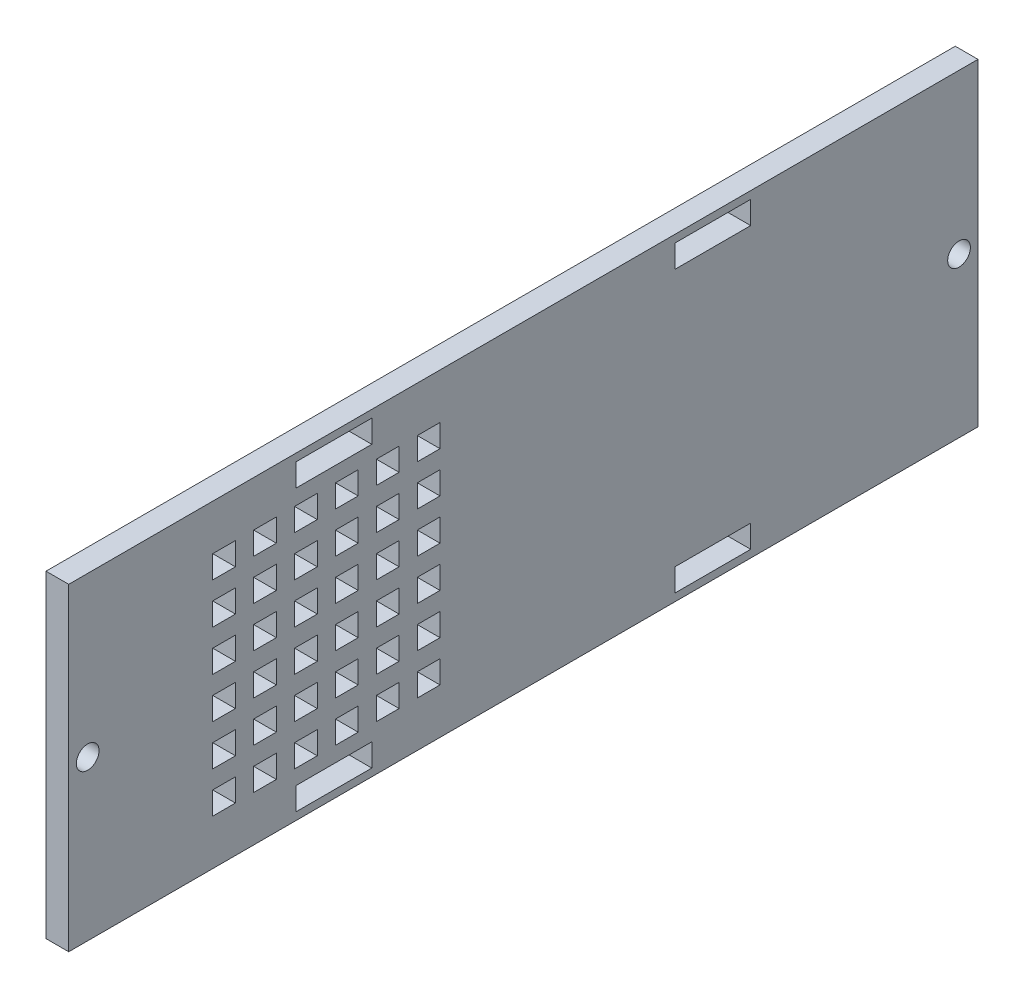
from build123d import *

# Parameters (mm, degrees)
SKETCH1_W            = 120
SKETCH1_H            = 42
SKETCH1_R            = 1.5
SKETCH1_W_2          = 10
SKETCH1_H_2          = 3
BOSS_EXTRUDE1_DEPTH  = 3
SKETCH2_W            = 3
SKETCH2_H            = 3
CUT_EXTRUDE1_DEPTH   = 3
LPATTERN1_COUNT      = 6
LPATTERN1_PITCH      = 5.4
LPATTERN1_COUNT_DIR2 = 6
LPATTERN1_PITCH_DIR2 = 5.4


with BuildPart() as part:
    # Sketch1 → Boss-Extrude1 (new body)
    with BuildSketch(Plane(origin=(0, 0, 0), x_dir=(0, 0, -1), z_dir=(1, 0, 0))):
        Rectangle(SKETCH1_W, SKETCH1_H)
        with Locations((-57.5, 0)):
            Circle(SKETCH1_R, mode=Mode.SUBTRACT)
        with Locations((57.5, 0)):
            Circle(SKETCH1_R, mode=Mode.SUBTRACT)
        with Locations((25, 18.5)):
            Rectangle(SKETCH1_W_2, SKETCH1_H_2, mode=Mode.SUBTRACT)
        with Locations((-25, 18.5)):
            Rectangle(SKETCH1_W_2, SKETCH1_H_2, mode=Mode.SUBTRACT)
        with Locations((-25, -18.5)):
            Rectangle(SKETCH1_W_2, SKETCH1_H_2, mode=Mode.SUBTRACT)
        with Locations((25, -18.5)):
            Rectangle(SKETCH1_W_2, SKETCH1_H_2, mode=Mode.SUBTRACT)
    extrude(amount=BOSS_EXTRUDE1_DEPTH)

    # Sketch2 → Cut-Extrude1 (cut)
    with BuildSketch(Plane(origin=(3, 0, 0), x_dir=(0, 0, -1), z_dir=(1, 0, 0))):
        with Locations((-12.5, 13.5)):
            Rectangle(SKETCH2_W, SKETCH2_H)
    cut_extrude1 = extrude(amount=-CUT_EXTRUDE1_DEPTH, mode=Mode.SUBTRACT)

    # LPattern1: Cut-Extrude1 6 × 6
    with Locations(*[(0, -j * LPATTERN1_PITCH_DIR2, i * LPATTERN1_PITCH) for i in range(LPATTERN1_COUNT) for j in range(LPATTERN1_COUNT_DIR2) if (i, j) != (0, 0)]):
        add(cut_extrude1, mode=Mode.SUBTRACT)


solid = part.part
